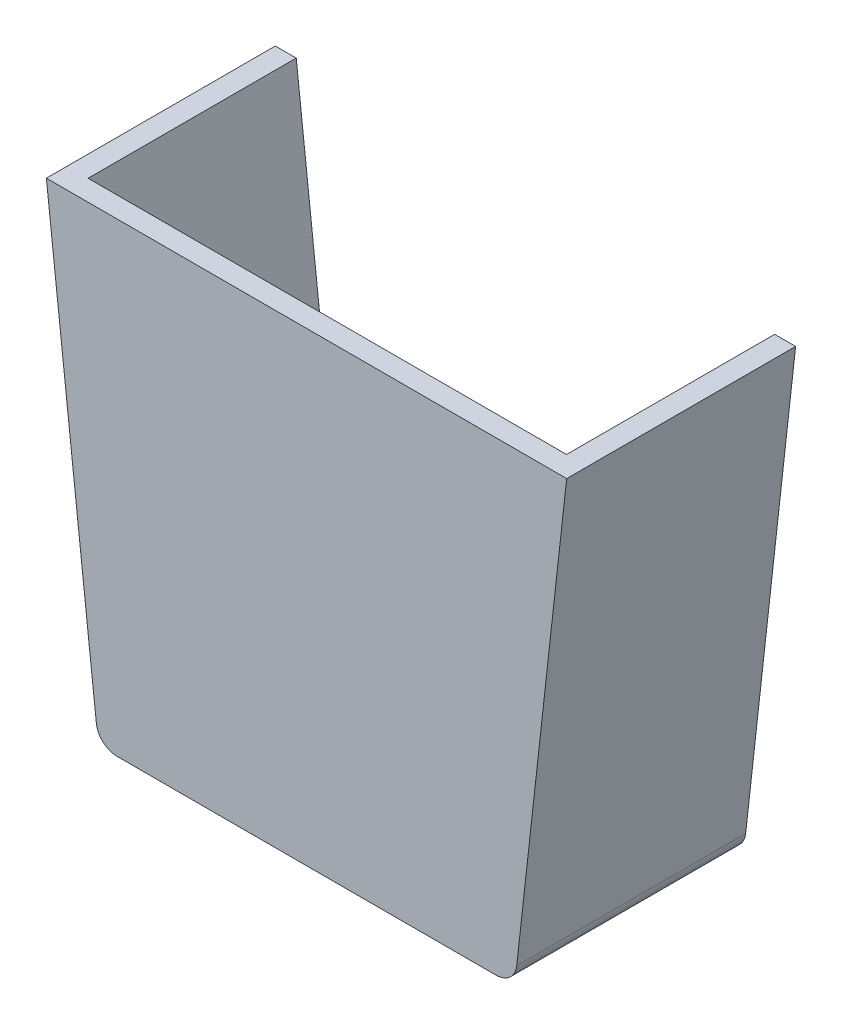
from build123d import *

# Parameters (mm, degrees)
BOSS_EXTRUDE1_DEPTH = 5.08
BOSS_EXTRUDE2_DEPTH = 50.8


with BuildPart() as part:
    # Sketch1 → Boss-Extrude1 (new body)
    with BuildSketch(Plane.XY):
        with BuildLine():
            Line((63.5, 56.7961272), (-63.5, 56.7961272))
            Line((-63.5, 56.7961272), (-51.304854459, -52.280570501))
            ThreePointArc((-51.304854459, -52.280570501), (-49.642976536, -55.502534499), (-46.25630987, -56.796126057))
            Line((-46.25630987, -56.796126057), (46.25630987, -56.796126057))
            ThreePointArc((46.25630987, -56.796126057), (49.642976536, -55.502534499), (51.304854459, -52.280570501))
            Line((51.304854459, -52.280570501), (63.5, 56.7961272))
        make_face()
    extrude(amount=-BOSS_EXTRUDE1_DEPTH)

    # Sketch2 → Boss-Extrude2 (add)
    with BuildSketch(Plane.XY.offset(-5.08)):
        with BuildLine():
            Line((-58.388346598, 56.7961272), (-63.49999326, 56.7961272))
            Line((-63.49999326, 56.7961272), (-51.304854494, -52.280570501))
            ThreePointArc((-51.304854494, -52.280570501), (-49.642976653, -55.502534705), (-46.25630987, -56.796126367))
            Line((-46.25630987, -56.796126367), (46.256310984, -56.796126367))
            ThreePointArc((46.256310984, -56.796126367), (49.642977767, -55.502534705), (51.304855608, -52.280570501))
            Line((51.304855608, -52.280570501), (63.499994374, 56.7961272))
            Line((63.499994374, 56.7961272), (58.388347712, 56.7961272))
            Line((58.388347712, 56.7961272), (46.761165369, -47.200570717))
            ThreePointArc((46.761165369, -47.200570717), (45.099287471, -50.422534777), (41.712620769, -51.716126367))
            Line((41.712620769, -51.716126367), (-41.712619655, -51.716126367))
            ThreePointArc((-41.712619655, -51.716126367), (-45.099286356, -50.422534777), (-46.761164254, -47.200570717))
            Line((-46.761164254, -47.200570717), (-58.388346598, 56.7961272))
        make_face()
    extrude(amount=-BOSS_EXTRUDE2_DEPTH)


solid = part.part
